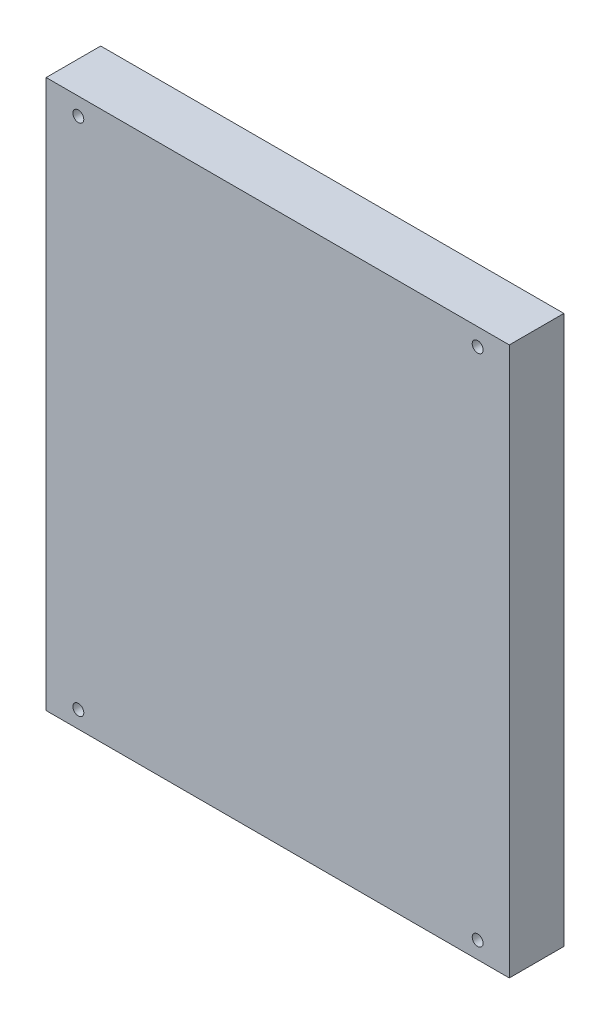
from build123d import *

# Parameters (mm, degrees)
ESQUISSE1_W             = 84.9
ESQUISSE1_H             = 100.5
BOSS_EXTRU_1_DEPTH      = 10
ESQUISSE2_R             = 1
ENL_V_MAT_EXTRU_1_DEPTH = 11


with BuildPart() as part:
    # Esquisse1 → Boss.-Extru.1 (new body)
    with BuildSketch(Plane.XY):
        with Locations((42.45, 50.25)):
            Rectangle(ESQUISSE1_W, ESQUISSE1_H)
    extrude(amount=BOSS_EXTRU_1_DEPTH)

    # Esquisse2 → Enlèv. mat.-Extru.1 (cut, through all)
    with BuildSketch(Plane.XY.offset(10)):
        with Locations((79.1, 97.3)):
            Circle(ESQUISSE2_R)
        with Locations((5.9, 97.3)):
            Circle(ESQUISSE2_R)
        with Locations((5.9, 3.1)):
            Circle(ESQUISSE2_R)
        with Locations((79.1, 3.1)):
            Circle(ESQUISSE2_R)
    extrude(amount=-ENL_V_MAT_EXTRU_1_DEPTH, mode=Mode.SUBTRACT)


solid = part.part
